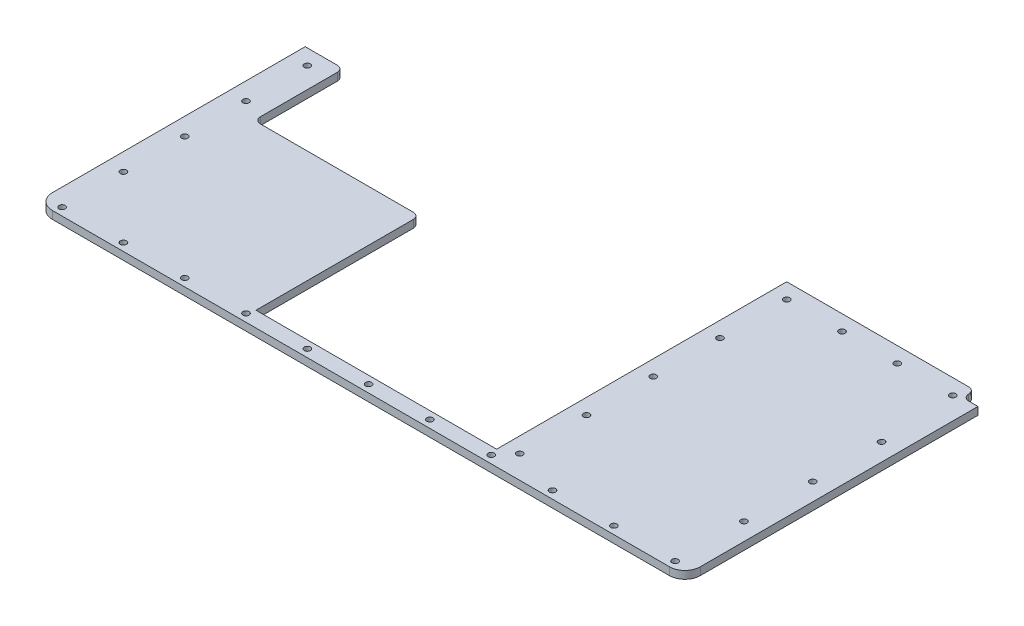
from build123d import *

# Parameters (mm, degrees)
BOSS_EXTRUDE1_DEPTH     = 1.5875
FILLET1_R               = 1.27
SKETCH2_R               = 0.635
CUT_EXTRUDE1_DEPTH      = 1
CUT_EXTRUDE1_DEPTH_BACK = 2.5875


with BuildPart() as part:
    # Sketch1 → Boss-Extrude1 (new body)
    with BuildSketch(Plane(origin=(0, 0, 0), x_dir=(1, 0, 0), z_dir=(0, 1, 0))):
        with BuildLine():
            Line((-66.675, 3.175), (-66.675, 55.209357386))
            Line((-66.675, 55.209357386), (-58.801, 55.209357386))
            Line((-58.801, 55.209357386), (-58.801, 36.83))
            Line((-58.801, 36.83), (-24.765, 36.83))
            Line((-24.765, 36.83), (-24.765, 3.175))
            Line((-24.765, 3.175), (24.765, 3.175))
            Line((24.765, 3.175), (24.765, 62.865))
            Line((24.765, 62.865), (62.23, 62.865))
            ThreePointArc((62.23, 62.865), (63.128025612, 62.493025612), (63.5, 61.595))
            ThreePointArc((63.5, 61.595), (63.871974388, 60.696974388), (64.77, 60.325))
            Line((64.77, 60.325), (66.675, 60.325))
            Line((66.675, 60.325), (66.675, 3.175))
            ThreePointArc((66.675, 3.175), (65.74506403, 0.92993597), (63.5, 0))
            Line((63.5, 0), (-63.5, 0))
            ThreePointArc((-63.5, 0), (-65.74506403, 0.92993597), (-66.675, 3.175))
        make_face()
    extrude(amount=BOSS_EXTRUDE1_DEPTH)

    # Fillet1
    fillet1_edges = [part.edges().sort_by_distance(p)[0] for p in [
        (-58.801, 0.79375, -55.209357386),
        (-58.801, 0.79375, -36.83),
        (-24.765, 0.79375, -36.83),
    ]]
    fillet(fillet1_edges, radius=FILLET1_R)

    # Sketch2 → Cut-Extrude1 (cut, two sides)
    with BuildSketch(Plane(origin=(0, 1.5875, 0), x_dir=(-1, 0, 0), z_dir=(0, 1, 0))) as cut_extrude1_sk:
        with Locations((63.074630657, -1.5875)):
            Circle(SKETCH2_R)
        with Locations((50.459704526, -1.5875)):
            Circle(SKETCH2_R)
        with Locations((37.844778394, -1.5875)):
            Circle(SKETCH2_R)
        with Locations((25.229852263, -1.5875)):
            Circle(SKETCH2_R)
        with Locations((12.614926131, -1.5875)):
            Circle(SKETCH2_R)
        with Locations((0, -1.5875)):
            Circle(SKETCH2_R)
        with Locations((-12.614926131, -1.5875)):
            Circle(SKETCH2_R)
        with Locations((-25.229852263, -1.5875)):
            Circle(SKETCH2_R)
        with Locations((-37.844778394, -1.5875)):
            Circle(SKETCH2_R)
        with Locations((-50.459704526, -1.5875)):
            Circle(SKETCH2_R)
        with Locations((-63.074630657, -1.5875)):
            Circle(SKETCH2_R)
        with Locations((63.074630657, -14.199214347)):
            Circle(SKETCH2_R)
        with Locations((63.074630657, -26.810928693)):
            Circle(SKETCH2_R)
        with Locations((63.074630657, -39.42264304)):
            Circle(SKETCH2_R)
        with Locations((63.074630657, -52.034357386)):
            Circle(SKETCH2_R)
        with Locations((-63.074630657, -15.750103912)):
            Circle(SKETCH2_R)
        with Locations((-63.074630657, -29.912707823)):
            Circle(SKETCH2_R)
        with Locations((-63.074630657, -44.075311735)):
            Circle(SKETCH2_R)
        with Locations((-62.100867444, -59.69)):
            Circle(SKETCH2_R)
        with Locations((-50.713911629, -59.69)):
            Circle(SKETCH2_R)
        with Locations((-39.326955815, -59.69)):
            Circle(SKETCH2_R)
        with Locations((-27.94, -59.69)):
            Circle(SKETCH2_R)
        with Locations((-27.94, -45.958125)):
            Circle(SKETCH2_R)
        with Locations((-27.94, -32.22625)):
            Circle(SKETCH2_R)
        with Locations((-27.94, -18.494375)):
            Circle(SKETCH2_R)
        with Locations((-27.94, -4.7625)):
            Circle(SKETCH2_R)
    extrude(amount=CUT_EXTRUDE1_DEPTH, mode=Mode.SUBTRACT)
    extrude(cut_extrude1_sk.sketch, amount=-CUT_EXTRUDE1_DEPTH_BACK, mode=Mode.SUBTRACT)


solid = part.part
